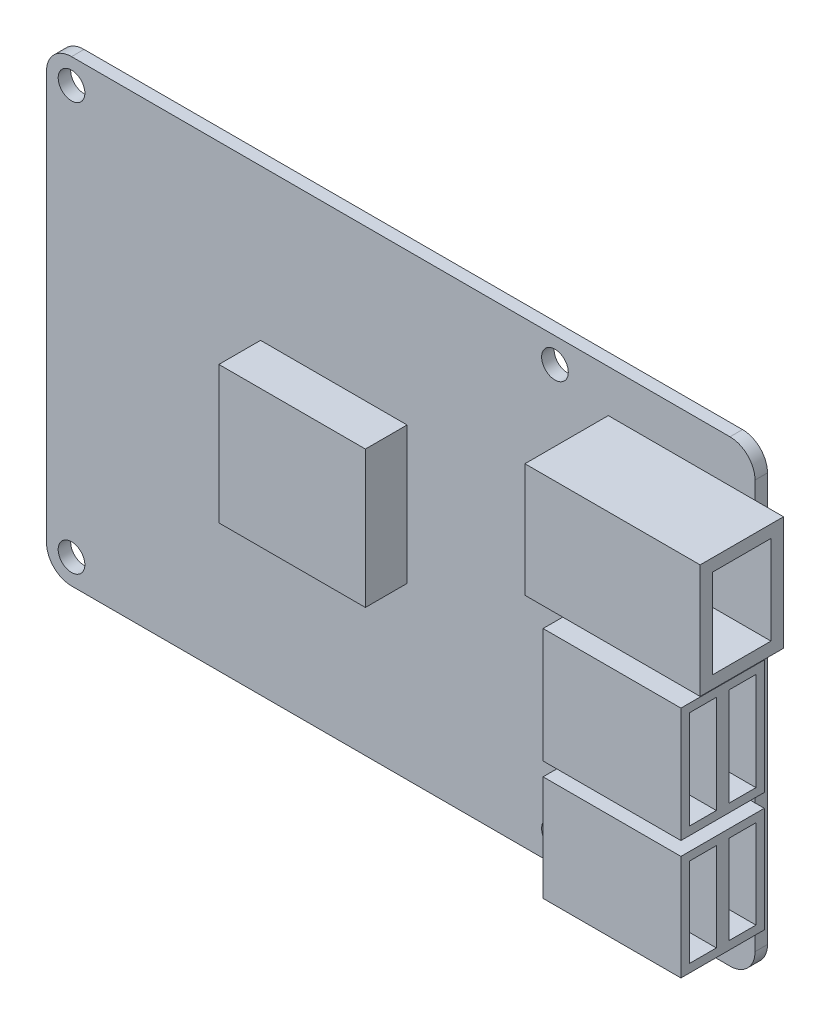
from build123d import *

# Parameters (mm, degrees)
SKETCH1_R           = 1.6
BOSS_EXTRUDE1_DEPTH = 1.5
SKETCH2_W           = 21.020817279
SKETCH2_H           = 13.668708773
SKETCH2_W_2         = 16.538575955
SKETCH2_H_2         = 13.76502595
SKETCH2_H_3         = 12.635061133
BOSS_EXTRUDE2_DEPTH = 10
SKETCH3_W           = 17.580136513
SKETCH3_H           = 16.463937369
BOSS_EXTRUDE3_DEPTH = 5
SKETCH4_W           = 7
SKETCH4_H           = 10.668708773
CUT_EXTRUDE1_DEPTH  = 15
SKETCH5_W           = 3.25
SKETCH5_H           = 10.635061133
SKETCH5_H_2         = 11.76502595
CUT_EXTRUDE2_DEPTH  = 15


with BuildPart() as part:
    # Sketch1 → Boss-Extrude1 (new body)
    with BuildSketch(Plane.XY):
        with BuildLine():
            Line((7.342063859, 25.576361327), (86.342063859, 25.576361327))
            ThreePointArc((86.342063859, 25.576361327), (88.463384202, 24.697681671), (89.342063859, 22.576361327))
            Line((89.342063859, 22.576361327), (89.342063859, -26.423638673))
            ThreePointArc((89.342063859, -26.423638673), (88.463384202, -28.544959016), (86.342063859, -29.423638673))
            Line((86.342063859, -29.423638673), (7.342063859, -29.423638673))
            ThreePointArc((7.342063859, -29.423638673), (5.220743515, -28.544959016), (4.342063859, -26.423638673))
            Line((4.342063859, -26.423638673), (4.342063859, 22.576361327))
            ThreePointArc((4.342063859, 22.576361327), (5.220743515, 24.697681671), (7.342063859, 25.576361327))
        make_face()
        with Locations((7.342063859, 22.576361327)):
            Circle(SKETCH1_R, mode=Mode.SUBTRACT)
        with Locations((7.342063859, -26.423638673)):
            Circle(SKETCH1_R, mode=Mode.SUBTRACT)
        with Locations((65.342063859, -26.423638673)):
            Circle(SKETCH1_R, mode=Mode.SUBTRACT)
        with Locations((65.342063859, 22.576361327)):
            Circle(SKETCH1_R, mode=Mode.SUBTRACT)
    extrude(amount=BOSS_EXTRUDE1_DEPTH)

    # Sketch2 → Boss-Extrude2 (add)
    with BuildSketch(Plane.XY.offset(1.5)):
        with Locations((82.249107191, 13.642831506)):
            Rectangle(SKETCH2_W, SKETCH2_H)
        with Locations((82.18632648, -2.437513953)):
            Rectangle(SKETCH2_W_2, SKETCH2_H_2)
        with Locations((82.18632648, -17.281142683)):
            Rectangle(SKETCH2_W_2, SKETCH2_H_3)
    extrude(amount=BOSS_EXTRUDE2_DEPTH)

    # Sketch3 → Boss-Extrude3 (add)
    with BuildSketch(Plane.XY.offset(1.5)):
        with Locations((38.810601532, -0.796926727)):
            Rectangle(SKETCH3_W, SKETCH3_H)
    extrude(amount=BOSS_EXTRUDE3_DEPTH)

    # Sketch4 → Cut-Extrude1 (cut)
    with BuildSketch(Plane(origin=(92.75951583, 0, 0), x_dir=(0, 0, -1), z_dir=(1, 0, 0))):
        with Locations((-6.5, 13.642831506)):
            Rectangle(SKETCH4_W, SKETCH4_H)
    extrude(amount=-CUT_EXTRUDE1_DEPTH, mode=Mode.SUBTRACT)

    # Sketch5 → Cut-Extrude2 (cut)
    with BuildSketch(Plane(origin=(90.455614457, 0, 0), x_dir=(0, 0, -1), z_dir=(1, 0, 0))):
        with Locations((-4.125, -17.281142683)):
            Rectangle(SKETCH5_W, SKETCH5_H)
        with Locations((-8.875, -17.281142683)):
            Rectangle(SKETCH5_W, SKETCH5_H)
        with Locations((-4.125, -2.437513953)):
            Rectangle(SKETCH5_W, SKETCH5_H_2)
        with Locations((-8.875, -2.437513953)):
            Rectangle(SKETCH5_W, SKETCH5_H_2)
    extrude(amount=-CUT_EXTRUDE2_DEPTH, mode=Mode.SUBTRACT)


solid = part.part
